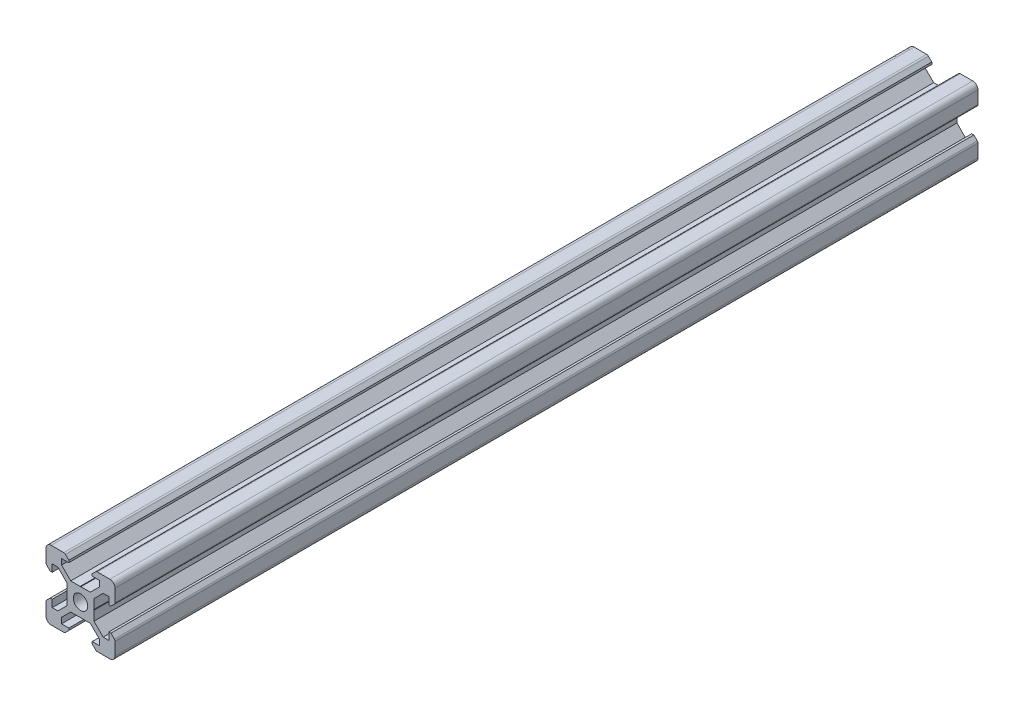
from build123d import *

# Parameters (mm, degrees)
SKETCH1_R           = 2.1
BOSS_EXTRUDE1_DEPTH = 250


with BuildPart() as part:
    # Sketch1 → Boss-Extrude1 (new body)
    with BuildSketch(Plane.XY):
        with BuildLine():
            Line((-8.5, 10), (-4.862792737, 10))
            ThreePointArc((-4.862792737, 10), (-4.598292737, 9.947387679), (-4.374060464, 9.797560464))
            Line((-4.374060464, 9.797560464), (-3.3865, 8.81))
            Line((-3.3865, 8.81), (-3.3865, 8.2))
            Line((-3.3865, 8.2), (-5.5, 8.2))
            Line((-5.5, 8.2), (-5.5, 6.561))
            Line((-5.5, 6.561), (-2.8395, 3.9005))
            Line((-2.8395, 3.9005), (-0.1, 3.9005))
            Line((-0.1, 3.9005), (0, 3.8005))
            Line((0, 3.8005), (0.1, 3.9005))
            Line((0.1, 3.9005), (2.8395, 3.9005))
            Line((2.8395, 3.9005), (5.5, 6.561))
            Line((5.5, 6.561), (5.5, 8.2))
            Line((5.5, 8.2), (3.3865, 8.2))
            Line((3.3865, 8.2), (3.3865, 8.81))
            Line((3.3865, 8.81), (4.374060464, 9.797560464))
            ThreePointArc((4.374060464, 9.797560464), (4.598292737, 9.947387679), (4.862792737, 10))
            Line((4.862792737, 10), (8.5, 10))
            ThreePointArc((8.5, 10), (9.560660172, 9.560660172), (10, 8.5))
            Line((10, 8.5), (10, 4.862792737))
            ThreePointArc((10, 4.862792737), (9.947387679, 4.598292737), (9.797560464, 4.374060464))
            Line((9.797560464, 4.374060464), (8.81, 3.3865))
            Line((8.81, 3.3865), (8.2, 3.3865))
            Line((8.2, 3.3865), (8.2, 5.5))
            Line((8.2, 5.5), (6.561, 5.5))
            Line((6.561, 5.5), (3.9005, 2.8395))
            Line((3.9005, 2.8395), (3.9005, 0.1))
            Line((3.9005, 0.1), (3.8005, 0))
            Line((3.8005, 0), (3.9005, -0.1))
            Line((3.9005, -0.1), (3.9005, -2.8395))
            Line((3.9005, -2.8395), (6.561, -5.5))
            Line((6.561, -5.5), (8.2, -5.5))
            Line((8.2, -5.5), (8.2, -3.3865))
            Line((8.2, -3.3865), (8.81, -3.3865))
            Line((8.81, -3.3865), (9.797560464, -4.374060464))
            ThreePointArc((9.797560464, -4.374060464), (9.947387679, -4.598292737), (10, -4.862792737))
            Line((10, -4.862792737), (10, -8.5))
            ThreePointArc((10, -8.5), (9.560660172, -9.560660172), (8.5, -10))
            Line((8.5, -10), (4.862792737, -10))
            ThreePointArc((4.862792737, -10), (4.598292737, -9.947387679), (4.374060464, -9.797560464))
            Line((4.374060464, -9.797560464), (3.3865, -8.81))
            Line((3.3865, -8.81), (3.3865, -8.2))
            Line((3.3865, -8.2), (5.5, -8.2))
            Line((5.5, -8.2), (5.5, -6.561))
            Line((5.5, -6.561), (2.8395, -3.9005))
            Line((2.8395, -3.9005), (0.1, -3.9005))
            Line((0.1, -3.9005), (0, -3.8005))
            Line((0, -3.8005), (-0.1, -3.9005))
            Line((-0.1, -3.9005), (-2.8395, -3.9005))
            Line((-2.8395, -3.9005), (-5.5, -6.561))
            Line((-5.5, -6.561), (-5.5, -8.2))
            Line((-5.5, -8.2), (-3.3865, -8.2))
            Line((-3.3865, -8.2), (-3.3865, -8.81))
            Line((-3.3865, -8.81), (-4.374060464, -9.797560464))
            ThreePointArc((-4.374060464, -9.797560464), (-4.598292737, -9.947387679), (-4.862792737, -10))
            Line((-4.862792737, -10), (-8.5, -10))
            ThreePointArc((-8.5, -10), (-9.560660172, -9.560660172), (-10, -8.5))
            Line((-10, -8.5), (-10, -4.862792737))
            ThreePointArc((-10, -4.862792737), (-9.947387679, -4.598292737), (-9.797560464, -4.374060464))
            Line((-9.797560464, -4.374060464), (-8.81, -3.3865))
            Line((-8.81, -3.3865), (-8.2, -3.3865))
            Line((-8.2, -3.3865), (-8.2, -5.5))
            Line((-8.2, -5.5), (-6.561, -5.5))
            Line((-6.561, -5.5), (-3.9005, -2.8395))
            Line((-3.9005, -2.8395), (-3.9005, -0.1))
            Line((-3.9005, -0.1), (-3.8005, 0))
            Line((-3.8005, 0), (-3.9005, 0.1))
            Line((-3.9005, 0.1), (-3.9005, 2.8395))
            Line((-3.9005, 2.8395), (-6.561, 5.5))
            Line((-6.561, 5.5), (-8.2, 5.5))
            Line((-8.2, 5.5), (-8.2, 3.3865))
            Line((-8.2, 3.3865), (-8.81, 3.3865))
            Line((-8.81, 3.3865), (-9.797560464, 4.374060464))
            ThreePointArc((-9.797560464, 4.374060464), (-9.947387679, 4.598292737), (-10, 4.862792737))
            Line((-10, 4.862792737), (-10, 8.5))
            ThreePointArc((-10, 8.5), (-9.560660172, 9.560660172), (-8.5, 10))
        make_face()
        Circle(SKETCH1_R, mode=Mode.SUBTRACT)
    extrude(amount=BOSS_EXTRUDE1_DEPTH)


solid = part.part
